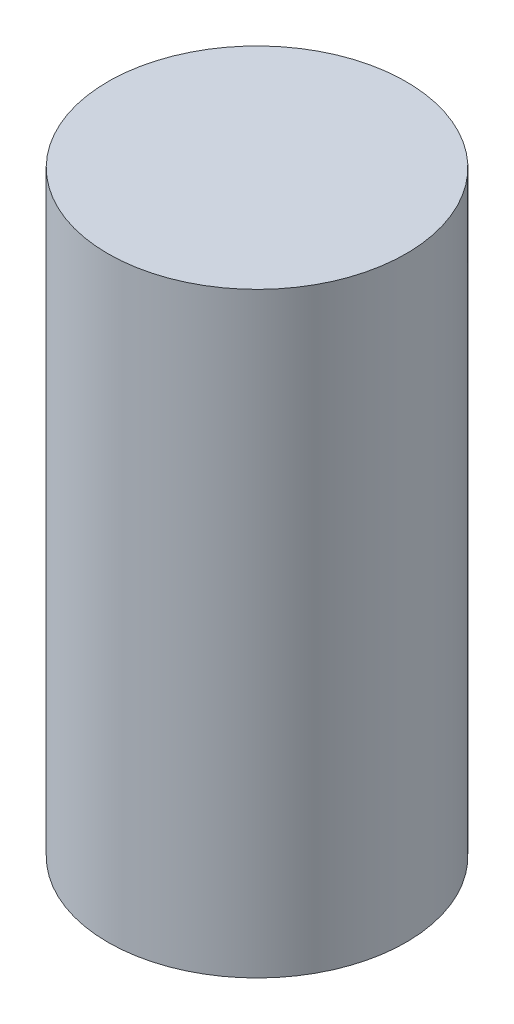
from build123d import *

# Parameters (mm, degrees)
SKETCH1_R           = 5
BOSS_EXTRUDE1_DEPTH = 20


with BuildPart() as part:
    # Sketch1 → Boss-Extrude1 (new body)
    with BuildSketch(Plane(origin=(0, 0, 0), x_dir=(1, 0, 0), z_dir=(0, 1, 0))):
        Circle(SKETCH1_R)
    extrude(amount=BOSS_EXTRUDE1_DEPTH)


solid = part.part
